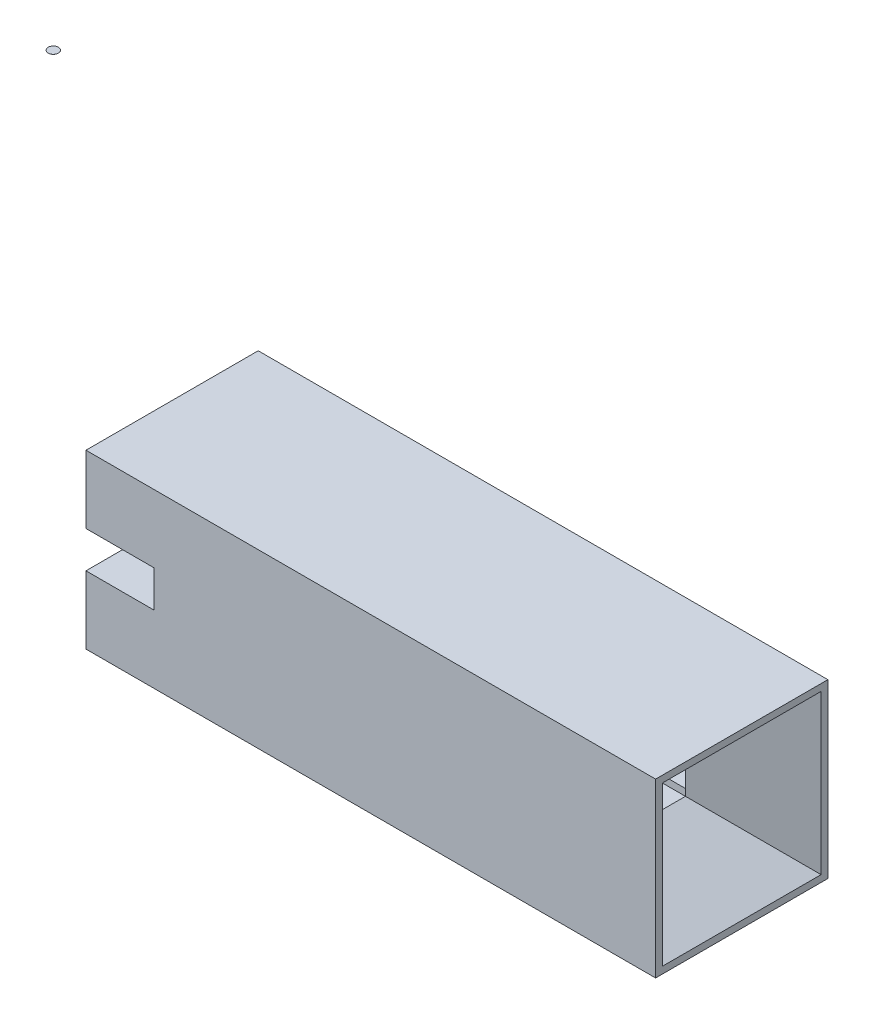
from build123d import *

# Parameters (mm, degrees)
SKETCH1_W                       = 8.4
SKETCH1_H                       = 2.54
BOSS_EXTRUDE1_DEPTH             = 2.54
CUT_EXTRUDE1_REACH              = 10.4
SKETCH2_W                       = 0.74
SKETCH2_H                       = 0.74
CHAMFER2_SIZE                   = 0.8
CHAMFER2_SIZE2                  = 1.2
SKETCH3_W                       = 2.54
SKETCH3_H                       = 0.54
CUT_EXTRUDE2_DEPTH              = 1
CUT_EXTRUDE4_START              = -6.2
SKETCH5_W                       = 1.74
SKETCH5_H                       = 0.54
CUT_EXTRUDE4_DEPTH              = 6.2
AUFSATZ_LINEAR_START            = 3.596964
SKIZZE1_R                       = 0.074999883
AUFSATZ_LINEAR_AUSTRAGEN1_DEPTH = 0.001


with BuildPart() as part:
    # Sketch1 → Boss-Extrude1 (new body)
    with BuildSketch(Plane.XY):
        with Locations((4.2, 1.27)):
            Rectangle(SKETCH1_W, SKETCH1_H)
    extrude(amount=BOSS_EXTRUDE1_DEPTH)

    # Sketch2 → Cut-Extrude1 (cut, up to next)
    with BuildSketch(Plane(origin=(8.4, 0, 0), x_dir=(0, 0, -1), z_dir=(1, 0, 0)), mode=Mode.PRIVATE) as cut_extrude1_sk1:
        with Locations((-1.27, 1.27)):
            Rectangle(SKETCH2_W, SKETCH2_H)
    cut_extrude1_tool1 = extrude(cut_extrude1_sk1.sketch, amount=-CUT_EXTRUDE1_REACH, mode=Mode.PRIVATE) & part.part
    add(cut_extrude1_tool1.solids().sort_by_distance((8.4, 1.27, 1.27))[0], mode=Mode.SUBTRACT)

    # Chamfer2
    chamfer2_edges = [part.edges().sort_by_distance(p)[0] for p in [
        (8.4, 1.27, 1.64),
        (8.4, 0.9, 1.27),
        (8.4, 1.27, 0.9),
        (8.4, 1.64, 1.27),
    ]]
    chamfer2_side = [part.faces().sort_by_distance(p)[0] for p in [
        (8.4, 0.035921024, 1.27),
    ]]
    chamfer(chamfer2_edges, length=CHAMFER2_SIZE, length2=CHAMFER2_SIZE2, reference=chamfer2_side[0])

    # Sketch3 → Cut-Extrude2 (cut)
    with BuildSketch(Plane.ZY):
        with Locations((1.27, 1.27)):
            Rectangle(SKETCH3_W, SKETCH3_H)
    extrude(amount=-CUT_EXTRUDE2_DEPTH, mode=Mode.SUBTRACT)

    # Sketch5 → Cut-Extrude4 (cut)
    with BuildSketch(Plane.ZY.offset(-1).offset(CUT_EXTRUDE4_START)):
        with Locations((1.27, 1.27)):
            Rectangle(SKETCH5_W, SKETCH5_H)
    extrude(amount=CUT_EXTRUDE4_DEPTH, mode=Mode.SUBTRACT)


with BuildPart() as body_2:
    # Skizze1 → Aufsatz-Linear austragen1 (new body)
    with BuildSketch(Plane(origin=(0, 2.54, 0), x_dir=(1, 0, 0), z_dir=(0, 1, 0)).offset(AUFSATZ_LINEAR_START)):
        with Locations((-1.751286424, -1.270014668)):
            Circle(SKIZZE1_R)
    extrude(amount=AUFSATZ_LINEAR_AUSTRAGEN1_DEPTH)


solid = Compound([part.part, body_2.part])
